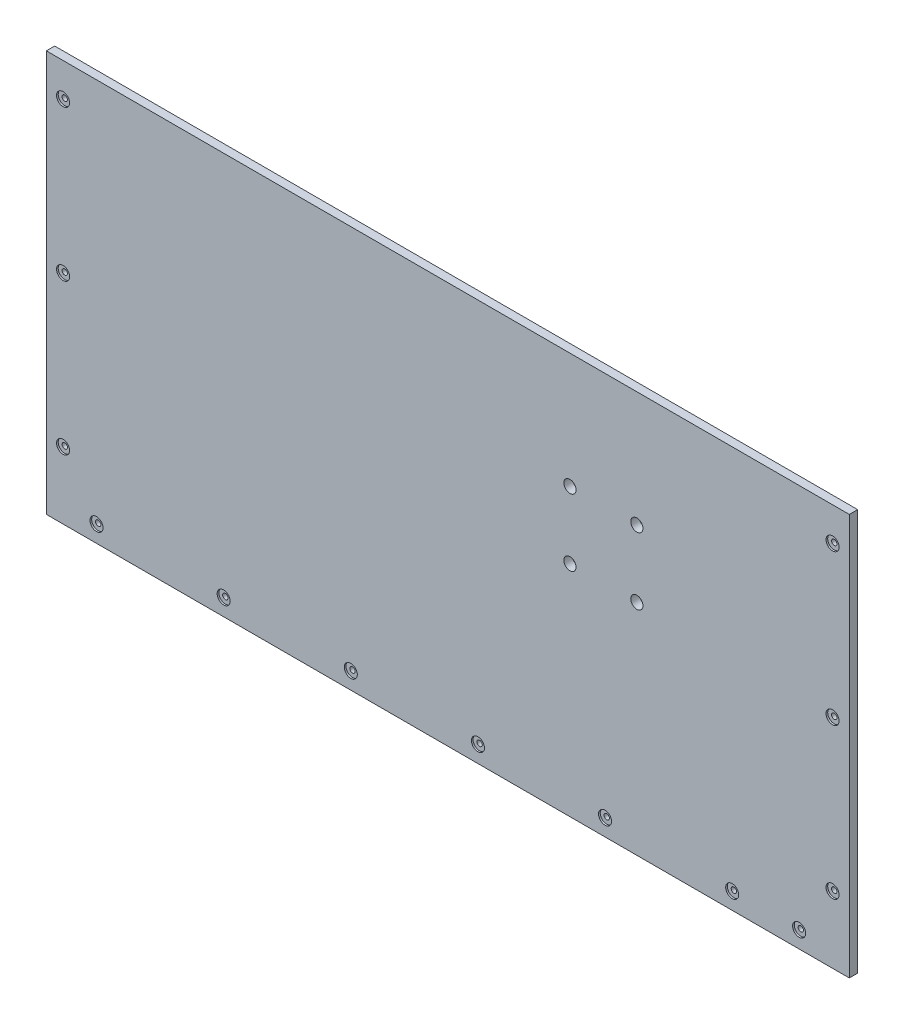
from build123d import *

# Parameters (mm, degrees)
SKETCH1_W           = 609.6
SKETCH1_H           = 304.8
BOSS_EXTRUDE1_DEPTH = 6.35
SKETCH2_R           = 4.6355
CUT_EXTRUDE1_DEPTH  = 7.35
SKETCH3_R           = 2.032
CUT_EXTRUDE2_DEPTH  = 7.35
SKETCH5_R           = 2.032
CUT_EXTRUDE3_DEPTH  = 7.35
SKETCH6_R           = 4.953
CUT_EXTRUDE4_DEPTH  = 1.27
SKETCH7_R           = 4.953
CUT_EXTRUDE5_DEPTH  = 1.27


with BuildPart() as part:
    # Sketch1 → Boss-Extrude1 (new body)
    with BuildSketch(Plane.XY):
        with Locations((-304.8, 152.4)):
            Rectangle(SKETCH1_W, SKETCH1_H)
    extrude(amount=BOSS_EXTRUDE1_DEPTH)

    # Sketch2 → Cut-Extrude1 (cut, through all)
    with BuildSketch(Plane.XY.offset(6.35)):
        with Locations((-161.29, 217.17)):
            Circle(SKETCH2_R)
        with Locations((-212.09, 217.17)):
            Circle(SKETCH2_R)
        with Locations((-161.29, 166.37)):
            Circle(SKETCH2_R)
        with Locations((-212.09, 166.37)):
            Circle(SKETCH2_R)
    extrude(amount=-CUT_EXTRUDE1_DEPTH, mode=Mode.SUBTRACT)

    # Sketch3 → Cut-Extrude2 (cut, through all)
    with BuildSketch(Plane.XY.offset(6.35)):
        with Locations((-596.9, 279.4)):
            Circle(SKETCH3_R)
        with Locations((-596.9, 165.1)):
            Circle(SKETCH3_R)
        with Locations((-596.9, 50.8)):
            Circle(SKETCH3_R)
        with Locations((-12.7, 50.8)):
            Circle(SKETCH3_R)
        with Locations((-12.7, 165.1)):
            Circle(SKETCH3_R)
        with Locations((-12.7, 279.4)):
            Circle(SKETCH3_R)
    extrude(amount=-CUT_EXTRUDE2_DEPTH, mode=Mode.SUBTRACT)

    # Sketch5 → Cut-Extrude3 (cut, through all)
    with BuildSketch(Plane.XY.offset(6.35)):
        with Locations((-571.5, 12.7)):
            Circle(SKETCH5_R)
        with Locations((-38.1, 12.7)):
            Circle(SKETCH5_R)
        with Locations((-474.98, 12.7)):
            Circle(SKETCH5_R)
        with Locations((-378.46, 12.7)):
            Circle(SKETCH5_R)
        with Locations((-281.94, 12.7)):
            Circle(SKETCH5_R)
        with Locations((-185.42, 12.7)):
            Circle(SKETCH5_R)
        with Locations((-88.9, 12.7)):
            Circle(SKETCH5_R)
    extrude(amount=-CUT_EXTRUDE3_DEPTH, mode=Mode.SUBTRACT)

    # Sketch6 → Cut-Extrude4 (cut)
    with BuildSketch(Plane.XY.offset(6.35)):
        with Locations((-596.9, 279.4)):
            Circle(SKETCH6_R)
        with Locations((-596.9, 165.1)):
            Circle(SKETCH6_R)
        with Locations((-596.9, 50.8)):
            Circle(SKETCH6_R)
        with Locations((-12.7, 50.8)):
            Circle(SKETCH6_R)
        with Locations((-12.7, 165.1)):
            Circle(SKETCH6_R)
        with Locations((-12.7, 279.4)):
            Circle(SKETCH6_R)
    extrude(amount=-CUT_EXTRUDE4_DEPTH, mode=Mode.SUBTRACT)

    # Sketch7 → Cut-Extrude5 (cut)
    with BuildSketch(Plane.XY.offset(6.35)):
        with Locations((-571.5, 12.7)):
            Circle(SKETCH7_R)
        with Locations((-474.98, 12.7)):
            Circle(SKETCH7_R)
        with Locations((-378.46, 12.7)):
            Circle(SKETCH7_R)
        with Locations((-281.94, 12.7)):
            Circle(SKETCH7_R)
        with Locations((-185.42, 12.7)):
            Circle(SKETCH7_R)
        with Locations((-88.9, 12.7)):
            Circle(SKETCH7_R)
        with Locations((-38.1, 12.7)):
            Circle(SKETCH7_R)
    extrude(amount=-CUT_EXTRUDE5_DEPTH, mode=Mode.SUBTRACT)


solid = part.part
